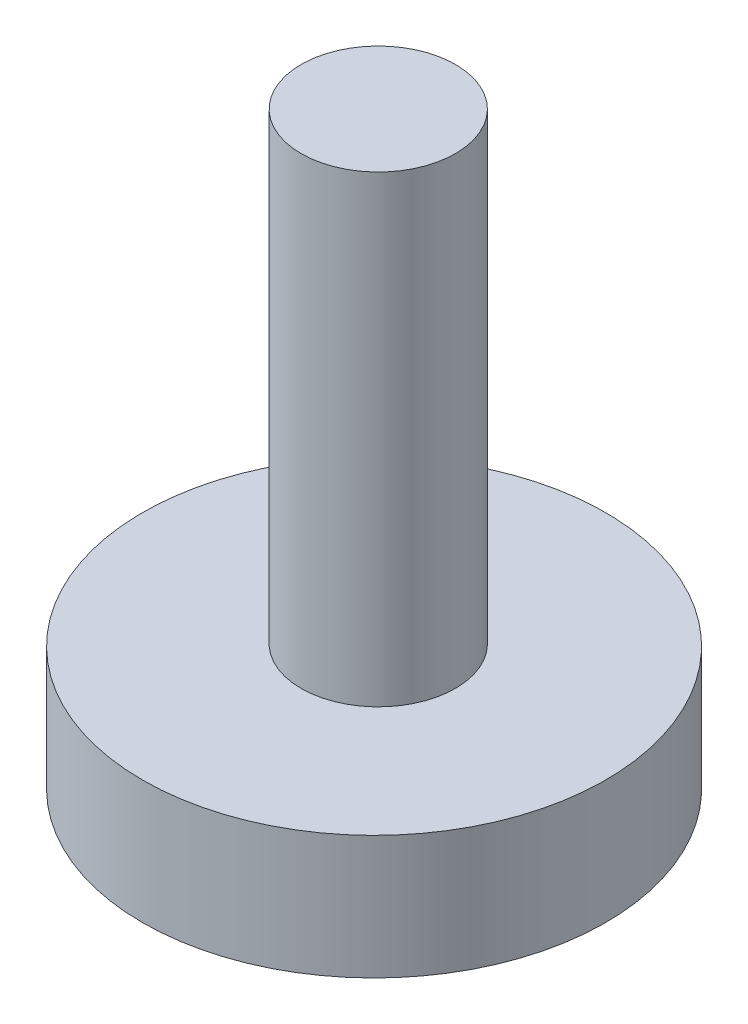
from build123d import *

# Parameters (mm, degrees)
SKETCH_1_R      = 7.5
EXTRUDE_1_DEPTH = 4
SKETCH_2_R      = 2.5
EXTRUDE_2_DEPTH = 15


with BuildPart() as part:
    # Эскиз1 → Бобышка-Вытянуть1 (new body)
    with BuildSketch(Plane(origin=(0, 0, 0), x_dir=(1, 0, 0), z_dir=(0, 1, 0))):
        Circle(SKETCH_1_R)
    extrude(amount=EXTRUDE_1_DEPTH)

    # Эскиз2 → Бобышка-Вытянуть2 (add)
    with BuildSketch(Plane(origin=(0, 4, 0), x_dir=(1, 0, 0), z_dir=(0, 1, 0))):
        with Locations((0, 0.136309696)):
            Circle(SKETCH_2_R)
    extrude(amount=EXTRUDE_2_DEPTH)


solid = part.part
